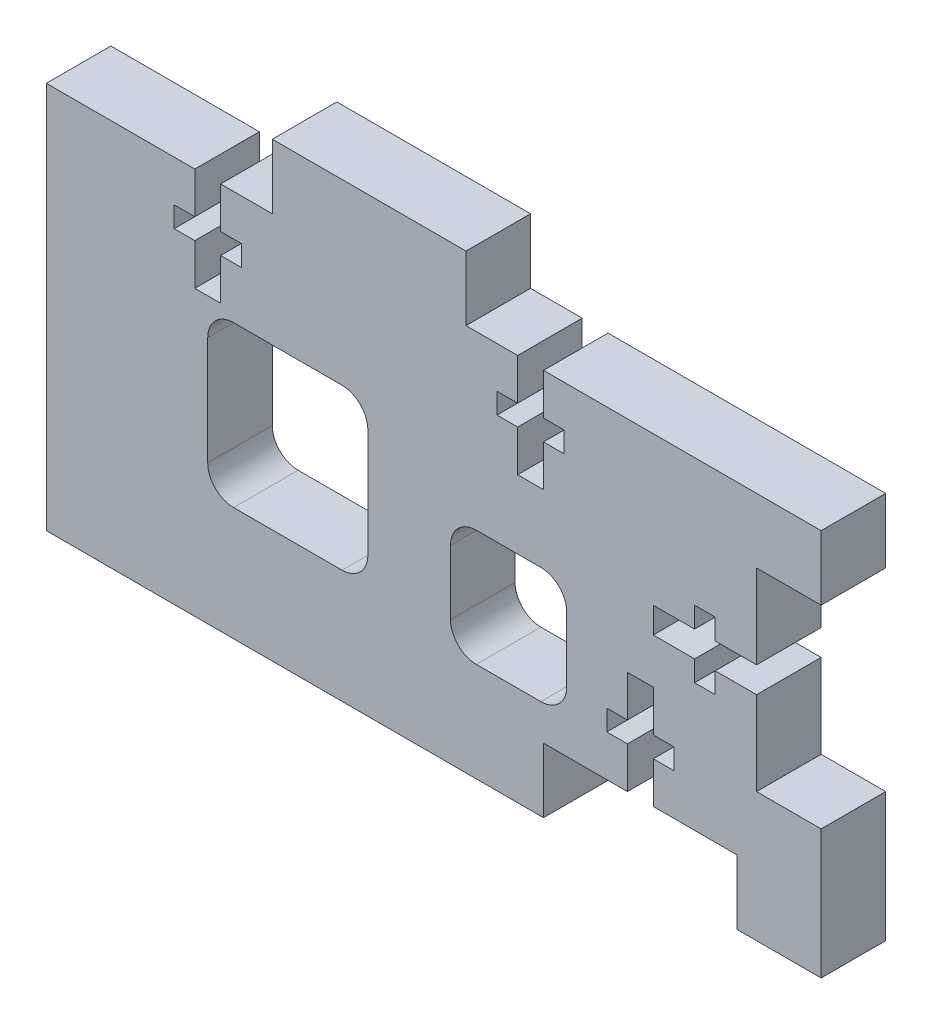
from build123d import *

# Parameters (mm, degrees)
SKETCH1_W               = 76.2
SKETCH1_H               = 31.75
BOSS_EXTRUDE1_DEPTH     = 6.35
SKETCH2_W               = 19.05
SKETCH2_H               = 6.35
BOSS_EXTRUDE2_DEPTH     = 6.35
CUT_EXTRUDE1_DEPTH      = 6.35
CUT_EXTRUDE4_DEPTH      = 6.35
SKETCH5_W               = 76.2
SKETCH5_H               = 6.35
BOSS_EXTRUDE3_DEPTH     = 6.35
CUT_EXTRUDE7_DEPTH      = 1
CUT_EXTRUDE7_DEPTH_BACK = 7.35


with BuildPart() as part:
    # Sketch1 → Boss-Extrude1 (new body)
    with BuildSketch(Plane.XY):
        Rectangle(SKETCH1_W, SKETCH1_H)
    extrude(amount=BOSS_EXTRUDE1_DEPTH)

    # Sketch2 → Boss-Extrude2 (add)
    with BuildSketch(Plane.XY.offset(6.35)):
        with Locations((-6.35, 19.05)):
            Rectangle(SKETCH2_W, SKETCH2_H)
    extrude(amount=-BOSS_EXTRUDE2_DEPTH)

    # Sketch3 → Cut-Extrude1 (cut)
    with BuildSketch(Plane.XY.offset(6.35)):
        Polygon((-20.955, 11.811), (-18.923, 11.811), (-18.923, 9.779), (-20.955, 9.779), (-20.955, 5.715), (-23.495, 5.715), (-23.495, 9.779), (-25.527, 9.779), (-25.527, 11.811), (-23.495, 11.811), (-23.495, 15.875), (-20.955, 15.875), align=None)
        Polygon((8.255, 9.779), (8.255, 5.715), (10.795, 5.715), (10.795, 9.779), (12.827, 9.779), (12.827, 11.811), (10.795, 11.811), (10.795, 15.875), (8.255, 15.875), (8.255, 11.811), (6.223, 11.811), (6.223, 9.779), align=None)
    extrude(amount=-CUT_EXTRUDE1_DEPTH, mode=Mode.SUBTRACT)

    # Sketch4 → Cut-Extrude4 (cut)
    with BuildSketch(Plane.XY.offset(6.35)):
        Polygon((31.75, -9.525), (38.1, -9.525), (38.1, 9.525), (31.75, 9.525), (31.75, 1.27), (27.686, 1.27), (27.686, 3.302), (25.654, 3.302), (25.654, 1.27), (21.59, 1.27), (21.59, -1.27), (25.654, -1.27), (25.654, -3.302), (27.686, -3.302), (27.686, -1.27), (31.75, -1.27), align=None)
    extrude(amount=-CUT_EXTRUDE4_DEPTH, mode=Mode.SUBTRACT)

    # Sketch5 → Boss-Extrude3 (add)
    with BuildSketch(Plane.XY.offset(6.35)):
        with Locations((0, -19.05)):
            Rectangle(SKETCH5_W, SKETCH5_H)
    extrude(amount=-BOSS_EXTRUDE3_DEPTH)

    # Sketch8 → Cut-Extrude7 (cut, two sides)
    with BuildSketch(Plane.XY.offset(6.35)) as cut_extrude7_sk:
        with BuildLine():
            Line((-19.685, 4.699), (-9.017, 4.699))
            ThreePointArc((-9.017, 4.699), (-7.220948776, 3.955051224), (-6.477, 2.159))
            Line((-6.477, 2.159), (-6.477, -8.509))
            ThreePointArc((-6.477, -8.509), (-7.220948776, -10.305051224), (-9.017, -11.049))
            Line((-9.017, -11.049), (-19.685, -11.049))
            ThreePointArc((-19.685, -11.049), (-21.481051224, -10.305051224), (-22.225, -8.509))
            Line((-22.225, -8.509), (-22.225, 2.159))
            ThreePointArc((-22.225, 2.159), (-21.481051224, 3.955051224), (-19.685, 4.699))
        make_face()
        Polygon((10.795, -15.875), (10.795, -22.225), (29.845, -22.225), (29.845, -15.875), (21.59, -15.875), (21.59, -11.811), (23.622, -11.811), (23.622, -9.779), (21.59, -9.779), (21.59, -5.715), (19.05, -5.715), (19.05, -9.779), (17.018, -9.779), (17.018, -11.811), (19.05, -11.811), (19.05, -15.875), align=None)
        with BuildLine():
            Line((4.191, -1.0414), (10.541, -1.0414))
            ThreePointArc((10.541, -1.0414), (12.337051224, -1.785348776), (13.081, -3.5814))
            Line((13.081, -3.5814), (13.081, -9.9314))
            ThreePointArc((13.081, -9.9314), (12.337051224, -11.727451224), (10.541, -12.4714))
            Line((10.541, -12.4714), (4.191, -12.4714))
            ThreePointArc((4.191, -12.4714), (2.394948776, -11.727451224), (1.651, -9.9314))
            Line((1.651, -9.9314), (1.651, -3.5814))
            ThreePointArc((1.651, -3.5814), (2.394948776, -1.785348776), (4.191, -1.0414))
        make_face()
    extrude(amount=CUT_EXTRUDE7_DEPTH, mode=Mode.SUBTRACT)
    extrude(cut_extrude7_sk.sketch, amount=-CUT_EXTRUDE7_DEPTH_BACK, mode=Mode.SUBTRACT)


solid = part.part
